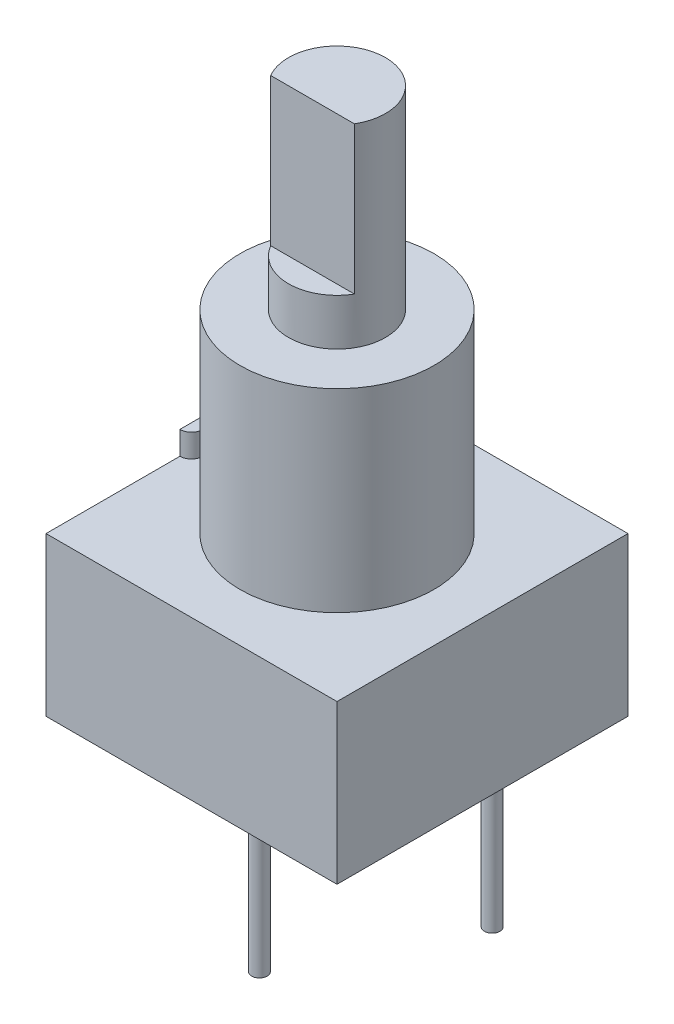
from build123d import *

# Parameters (mm, degrees)
SKETCH1_W           = 9.525
SKETCH1_H           = 9.525
BOSS_EXTRUDE1_DEPTH = 5.1816
SKETCH2_R           = 3.175
BOSS_EXTRUDE2_DEPTH = 6.35
BOSS_EXTRUDE3_DEPTH = 0.762
SKETCH4_R           = 1.5875
BOSS_EXTRUDE4_DEPTH = 6.35
CUT_EXTRUDE1_DEPTH  = 4.826
SKETCH6_R           = 0.254
BOSS_EXTRUDE5_DEPTH = 5.969


with BuildPart() as part:
    # Sketch1 → Boss-Extrude1 (new body)
    with BuildSketch(Plane(origin=(0, 0, 0), x_dir=(1, 0, 0), z_dir=(0, 1, 0))):
        Rectangle(SKETCH1_W, SKETCH1_H)
    extrude(amount=-BOSS_EXTRUDE1_DEPTH)

    # Sketch2 → Boss-Extrude2 (add)
    with BuildSketch(Plane(origin=(0, 0, 0), x_dir=(1, 0, 0), z_dir=(0, 1, 0))):
        Circle(SKETCH2_R)
    extrude(amount=BOSS_EXTRUDE2_DEPTH)

    # Sketch3 → Boss-Extrude3 (add)
    with BuildSketch(Plane(origin=(0, 0, 0), x_dir=(1, 0, 0), z_dir=(0, 1, 0))):
        with BuildLine():
            Line((-4.7625, 0.381), (-4.7625, -0.381))
            ThreePointArc((-4.7625, -0.381), (-4.3815, 0), (-4.7625, 0.381))
        make_face()
    extrude(amount=BOSS_EXTRUDE3_DEPTH)

    # Sketch4 → Boss-Extrude4 (add)
    with BuildSketch(Plane(origin=(0, 6.35, 0), x_dir=(1, 0, 0), z_dir=(0, 1, 0))):
        Circle(SKETCH4_R)
    extrude(amount=BOSS_EXTRUDE4_DEPTH)

    # Sketch5 → Cut-Extrude1 (cut)
    with BuildSketch(Plane(origin=(0, 12.7, 0), x_dir=(1, 0, 0), z_dir=(0, 1, 0))):
        with BuildLine():
            Line((-1.371129549, -0.8001), (1.371129549, -0.8001))
            ThreePointArc((1.371129549, -0.8001), (0, -1.5875), (-1.371129549, -0.8001))
        make_face()
    extrude(amount=-CUT_EXTRUDE1_DEPTH, mode=Mode.SUBTRACT)

    # Sketch6 → Boss-Extrude5 (add)
    with BuildSketch(Plane.XZ.offset(5.1816)):
        with Locations((0, 2.54)):
            Circle(SKETCH6_R)
        with Locations((-2.54, -2.54)):
            Circle(SKETCH6_R)
        with Locations((2.54, -2.54)):
            Circle(SKETCH6_R)
    extrude(amount=BOSS_EXTRUDE5_DEPTH)


solid = part.part
